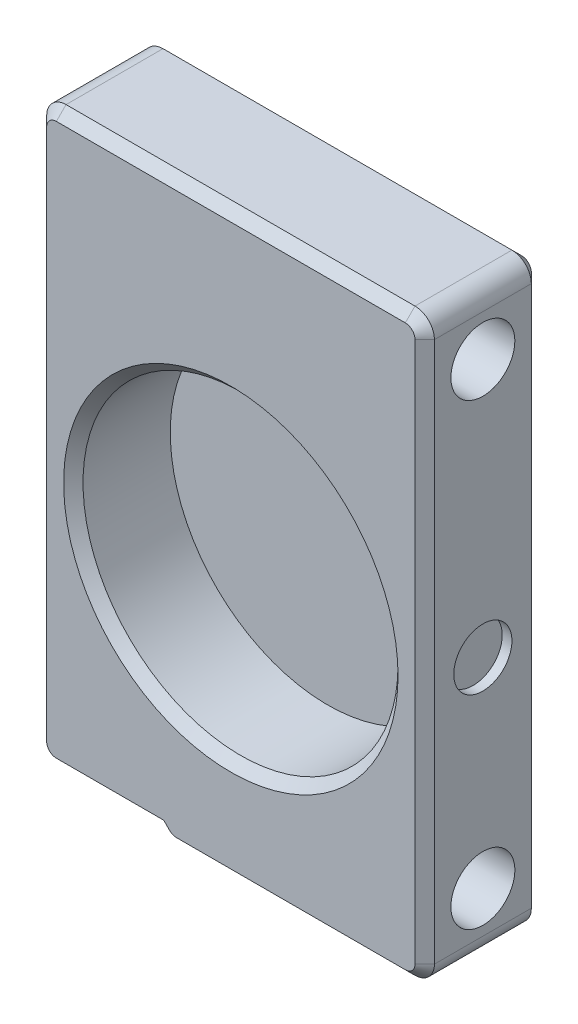
from build123d import *

# Parameters (mm, degrees)
BOSS_EXTRUDE1_DEPTH = 6
SKETCH2_R           = 8.125
CUT_EXTRUDE1_DEPTH  = 5
SKETCH3_R           = 1.5
CUT_EXTRUDE2_DEPTH  = 0.5
SKETCH4_R           = 1.65
CUT_EXTRUDE3_DEPTH  = 21
SKETCH5_W           = 20
SKETCH5_H           = 0.05
CUT_EXTRUDE4_DEPTH  = 7
FILLET1_R           = 1
CHAMFER1_SIZE       = 0.5


with BuildPart() as part:
    # Sketch1 → Boss-Extrude1 (new body)
    with BuildSketch(Plane.XY):
        Polygon((-3.170042294, -13.5), (10, -13.5), (10, 13.5), (10, 16.5), (-10, 16.5), (-10, 13.5), (-10, -13), (-3.670042294, -13), align=None)
    extrude(amount=BOSS_EXTRUDE1_DEPTH)

    # Sketch2 → Cut-Extrude1 (cut)
    with BuildSketch(Plane.XY.offset(6)):
        Circle(SKETCH2_R)
    extrude(amount=-CUT_EXTRUDE1_DEPTH, mode=Mode.SUBTRACT)

    # Sketch3 → Cut-Extrude2 (cut)
    with BuildSketch(Plane(origin=(10, 0, 0), x_dir=(0, 0, -1), z_dir=(1, 0, 0))):
        with Locations((-3, 0)):
            Circle(SKETCH3_R)
    extrude(amount=-CUT_EXTRUDE2_DEPTH, mode=Mode.SUBTRACT)

    # Sketch4 → Cut-Extrude3 (cut, through all)
    with BuildSketch(Plane(origin=(10, 0, 0), x_dir=(0, 0, -1), z_dir=(1, 0, 0))):
        with Locations((-3, 13.32)):
            Circle(SKETCH4_R)
        with Locations((-3, -10.31539104)):
            Circle(SKETCH4_R)
    extrude(amount=-CUT_EXTRUDE3_DEPTH, mode=Mode.SUBTRACT)

    # Sketch5 → Cut-Extrude4 (cut, through all)
    with BuildSketch(Plane(origin=(0, 0, 0), x_dir=(-1, 0, 0), z_dir=(0, 0, -1))):
        with Locations((0, 16.475)):
            Rectangle(SKETCH5_W, SKETCH5_H)
        with Locations((0, -13.475)):
            Rectangle(SKETCH5_W, SKETCH5_H)
    extrude(amount=-CUT_EXTRUDE4_DEPTH, mode=Mode.SUBTRACT)

    # Fillet1
    fillet1_edges = [part.edges().sort_by_distance(p)[0] for p in [
        (-10, -13, 3),
        (-10, 16.45, 3),
        (10, 16.45, 3),
        (-3.220042294, -13.45, 3),
        (10, -13.45, 3),
    ]]
    fillet(fillet1_edges, radius=FILLET1_R)

    # Chamfer1
    chamfer1_edges = [part.edges().sort_by_distance(p)[0] for p in [
        (-9.707106781, 16.157106781, 0),
        (9.707106781, -13.157106781, 0),
        (-3.188512164, -13.373879533, 0),
        (-3.591488904, -13.078553391, 6),
        (-8.125, 0, 6),
        (0, 16.45, 6),
        (-10, 1.725, 6),
        (-6.335021147, -13, 6),
        (3.097085634, -13.45, 6),
        (10, 1.5, 6),
        (-9.707106781, -12.707106781, 6),
        (9.707106781, 16.157106781, 6),
        (-9.707106781, 16.157106781, 6),
        (9.707106781, -13.157106781, 6),
        (-3.591488904, -13.078553391, 0),
        (-3.188512164, -13.373879533, 6),
        (3.097085634, -13.45, 0),
        (-10, 1.725, 0),
        (0, 16.45, 0),
        (10, 1.5, 0),
        (-6.335021147, -13, 0),
        (-9.707106781, -12.707106781, 0),
        (9.707106781, 16.157106781, 0),
    ]]
    chamfer(chamfer1_edges, length=CHAMFER1_SIZE)


solid = part.part
